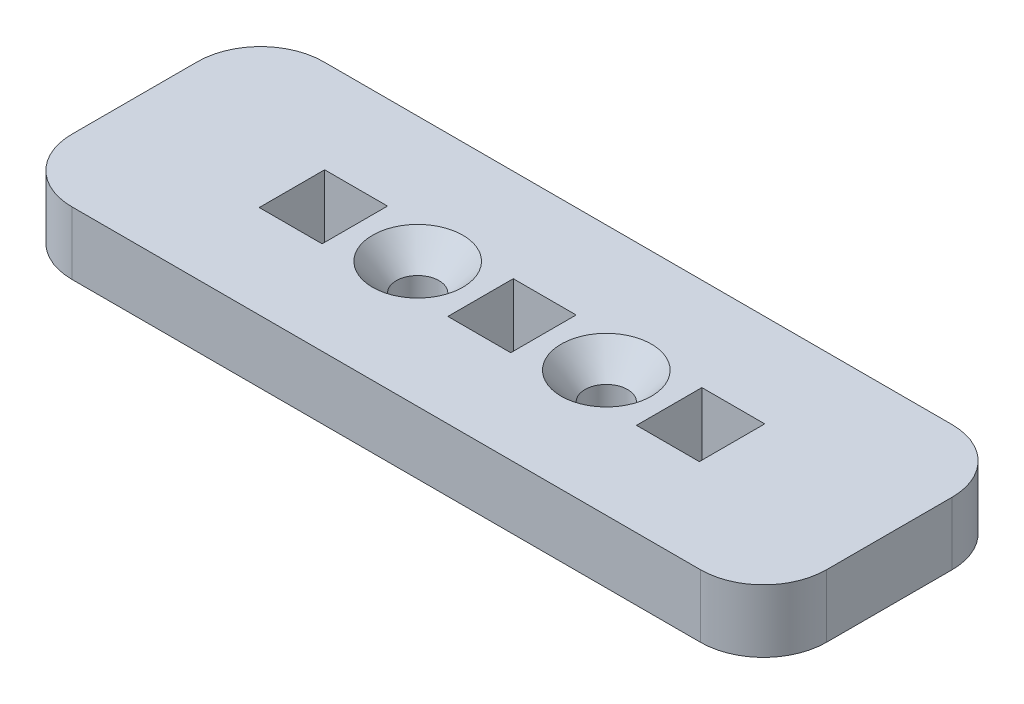
from build123d import *

# Parameters (mm, degrees)
SKETCH1_W                                         = 76.2
SKETCH1_H                                         = 25.4
BOSS_EXTRUDE1_DEPTH                               = 6.35
SKETCH2_R                                         = 2.15265
SKETCH2_W                                         = 6.35
SKETCH2_H                                         = 6.604
CUT_EXTRUDE1_DEPTH                                = 7.35
FILLET1_R                                         = 6.35
CSK_FOR_8_FLAT_HEAD_SOCKET_CAP_SCREW1_D           = 4.3053
CSK_FOR_8_FLAT_HEAD_SOCKET_CAP_SCREW1_CSINK_D     = 9.1186
CSK_FOR_8_FLAT_HEAD_SOCKET_CAP_SCREW1_CSINK_ANGLE = 82


with BuildPart() as part:
    # Sketch1 → Boss-Extrude1 (new body)
    with BuildSketch(Plane(origin=(0, 0, 0), x_dir=(1, 0, 0), z_dir=(0, 1, 0))):
        Rectangle(SKETCH1_W, SKETCH1_H)
    extrude(amount=BOSS_EXTRUDE1_DEPTH)

    # Sketch2 → Cut-Extrude1 (cut, through all)
    with BuildSketch(Plane(origin=(0, 6.35, 0), x_dir=(1, 0, 0), z_dir=(0, 1, 0))):
        with Locations((-9.525, 0)):
            Circle(SKETCH2_R)
        with Locations((9.525, 0)):
            Circle(SKETCH2_R)
        Rectangle(SKETCH2_W, SKETCH2_H)
        with Locations((-19.05, 0)):
            Rectangle(SKETCH2_W, SKETCH2_H)
        with Locations((19.05, 0)):
            Rectangle(SKETCH2_W, SKETCH2_H)
    extrude(amount=-CUT_EXTRUDE1_DEPTH, mode=Mode.SUBTRACT)

    # Fillet1
    fillet1_edges = [part.edges().sort_by_distance(p)[0] for p in [
        (-38.1, 3.175, -12.7),
        (38.1, 3.175, -12.7),
        (38.1, 3.175, 12.7),
        (-38.1, 3.175, 12.7),
    ]]
    fillet(fillet1_edges, radius=FILLET1_R)

    # CSK for #8 Flat Head Socket Cap Screw1 (through all)
    with Locations(Plane(origin=(0, 6.35, 0), x_dir=(1, 0, 0), z_dir=(0, 1, 0))):
        with Locations((-9.525, 0), (9.525, 0)):
            CounterSinkHole(CSK_FOR_8_FLAT_HEAD_SOCKET_CAP_SCREW1_D / 2, CSK_FOR_8_FLAT_HEAD_SOCKET_CAP_SCREW1_CSINK_D / 2, counter_sink_angle=CSK_FOR_8_FLAT_HEAD_SOCKET_CAP_SCREW1_CSINK_ANGLE)


solid = part.part
